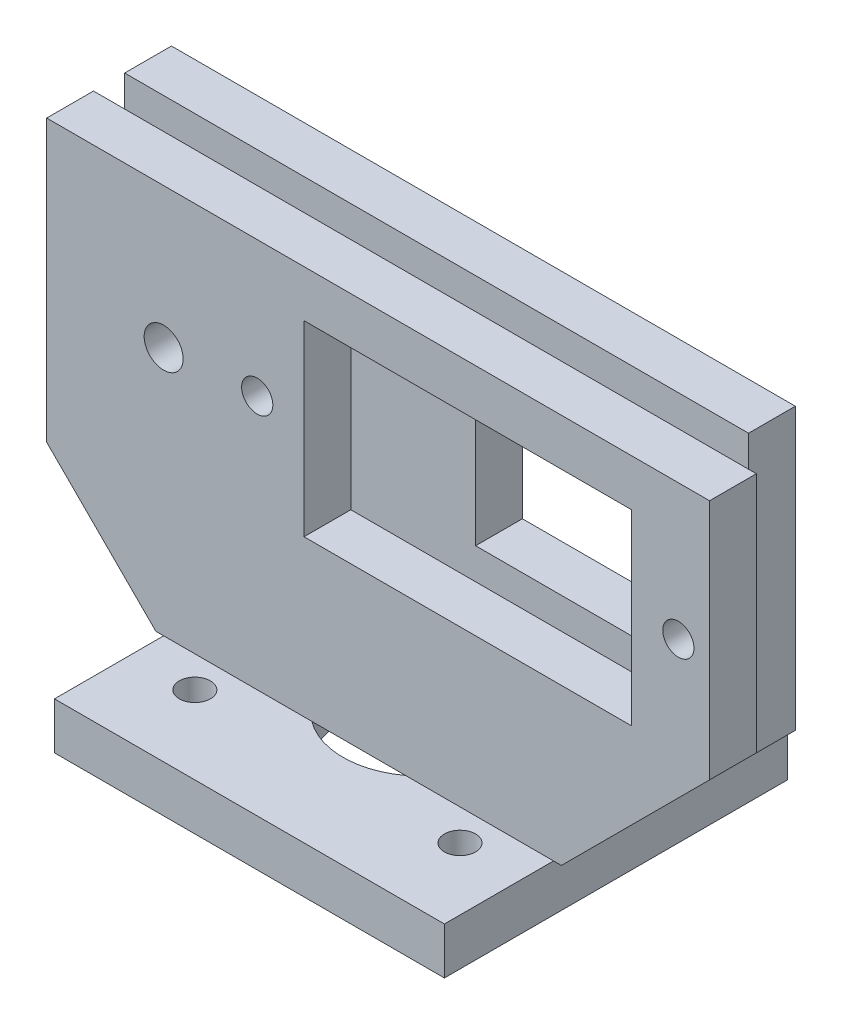
from build123d import *

# Parameters (mm, degrees)
SKETCH1_W           = 25
SKETCH1_H           = 22
SKETCH1_R           = 1
SKETCH1_R_2         = 5
BOSS_EXTRUDE1_DEPTH = 3
SKETCH2_W           = 40
SKETCH2_H           = 8
BOSS_EXTRUDE2_DEPTH = 25
CHAMFER1_SIZE       = 7
SKETCH3_W           = 40
SKETCH3_H           = 2
CUT_EXTRUDE1_DEPTH  = 25
SKETCH7_W           = 21
SKETCH7_H           = 12
CUT_EXTRUDE2_DEPTH  = 3
SKETCH8_W           = 15
SKETCH8_H           = 12
CUT_EXTRUDE3_DEPTH  = 31
SKETCH9_R           = 1.25
CUT_EXTRUDE4_DEPTH  = 31
BOSS_EXTRUDE3_START = -3
BOSS_EXTRUDE3_DEPTH = 3
SKETCH11_R          = 1
CUT_EXTRUDE5_DEPTH  = 3


with BuildPart() as part:
    # Sketch1 → Boss-Extrude1 (new body)
    with BuildSketch(Plane(origin=(0, 0, 0), x_dir=(1, 0, 0), z_dir=(0, 1, 0))):
        Rectangle(SKETCH1_W, SKETCH1_H)
        with Locations((6, 8)):
            Circle(SKETCH1_R, mode=Mode.SUBTRACT)
        with Locations((-6, 8)):
            Circle(SKETCH1_R, mode=Mode.SUBTRACT)
        Circle(SKETCH1_R_2, mode=Mode.SUBTRACT)
        with Locations((-8.5, -6)):
            Circle(SKETCH1_R, mode=Mode.SUBTRACT)
        with Locations((8.5, -6)):
            Circle(SKETCH1_R, mode=Mode.SUBTRACT)
    extrude(amount=BOSS_EXTRUDE1_DEPTH)

    # Sketch2 → Boss-Extrude2 (add)
    with BuildSketch(Plane(origin=(0, 3, 0), x_dir=(1, 0, 0), z_dir=(0, 1, 0))):
        Rectangle(SKETCH2_W, SKETCH2_H)
    extrude(amount=BOSS_EXTRUDE2_DEPTH)

    # Chamfer1
    chamfer1_edges = [part.edges().sort_by_distance(p)[0] for p in [
        (20, 3, 0),
        (-20, 3, 0),
    ]]
    chamfer(chamfer1_edges, length=CHAMFER1_SIZE)

    # Sketch3 → Cut-Extrude1 (cut)
    with BuildSketch(Plane(origin=(0, 28, 0), x_dir=(1, 0, 0), z_dir=(0, 1, 0))):
        Rectangle(SKETCH3_W, SKETCH3_H)
    extrude(amount=-CUT_EXTRUDE1_DEPTH, mode=Mode.SUBTRACT)

    # Sketch7 → Cut-Extrude2 (cut)
    with BuildSketch(Plane.XY.offset(4)):
        with Locations((7, 19)):
            Rectangle(SKETCH7_W, SKETCH7_H)
    extrude(amount=-CUT_EXTRUDE2_DEPTH, mode=Mode.SUBTRACT)

    # Sketch8 → Cut-Extrude3 (cut)
    with BuildSketch(Plane.XY.offset(-1)):
        with Locations((10, 19)):
            Rectangle(SKETCH8_W, SKETCH8_H)
    extrude(amount=-CUT_EXTRUDE3_DEPTH, mode=Mode.SUBTRACT)

    # Sketch9 → Cut-Extrude4 (cut)
    with BuildSketch(Plane.XY.offset(4)):
        with Locations((-12.5, 19)):
            Circle(SKETCH9_R)
    extrude(amount=-CUT_EXTRUDE4_DEPTH, mode=Mode.SUBTRACT)

    # Sketch10 → Boss-Extrude3 (add)
    with BuildSketch(Plane.XY.offset(4).offset(BOSS_EXTRUDE3_START)):
        Polygon((20, 10), (22.5, 12.5), (22.5, 28), (20, 28), align=None)
    extrude(amount=BOSS_EXTRUDE3_DEPTH)

    # Sketch11 → Cut-Extrude5 (cut)
    with BuildSketch(Plane.XY.offset(4)):
        with Locations((20.5, 19.311850015)):
            Circle(SKETCH11_R)
        with Locations((-6.5, 19.311850015)):
            Circle(SKETCH11_R)
    extrude(amount=-CUT_EXTRUDE5_DEPTH, mode=Mode.SUBTRACT)


solid = part.part
